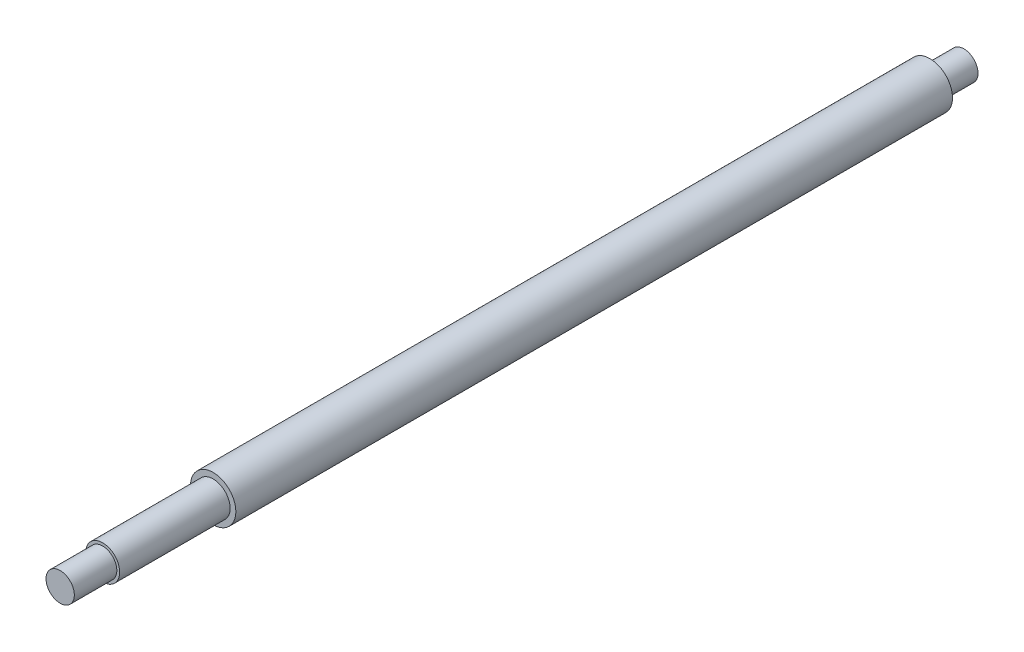
from build123d import *


with BuildPart() as part:
    # Sketch1 → Revolve1 (revolve)
    with BuildSketch(Plane(origin=(0, 0, 0), x_dir=(0, 0, -1), z_dir=(1, 0, 0))):
        Polygon((-318.98, 0), (-318.98, 5), (-303.98, 5), (-303.98, 6), (-264.98, 6), (-264.98, 8), (-12, 8), (-12, 5), (0, 5), (0, 0), align=None)
    revolve(axis=Axis((0, 0, 0), (0, 0, 1)))


solid = part.part
